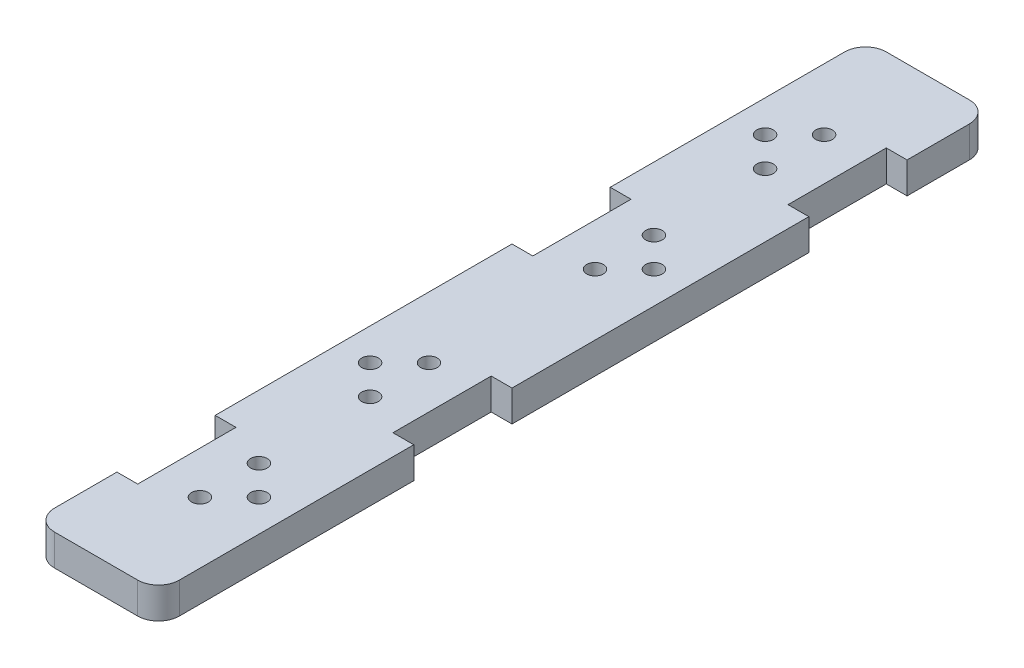
from build123d import *

# Parameters (mm, degrees)
BOSS_EXTRUDE1_DEPTH = 9.525
CUT_EXTRUDE1_REACH  = 11.525
SKETCH2_R           = 2.54
SKETCH2_W           = 6.35
SKETCH2_H           = 30


with BuildPart() as part:
    # Sketch1 → Boss-Extrude1 (new body)
    with BuildSketch(Plane(origin=(0, 0, 0), x_dir=(1, 0, 0), z_dir=(0, 1, 0))):
        with BuildLine():
            Line((6.35, 0), (31.75, 0))
            ThreePointArc((31.75, 0), (36.240128061, 1.859871939), (38.1, 6.35))
            Line((38.1, 6.35), (38.1, 247.65))
            ThreePointArc((38.1, 247.65), (36.240128061, 252.140128061), (31.75, 254))
            Line((31.75, 254), (6.35, 254))
            ThreePointArc((6.35, 254), (1.859871939, 252.140128061), (0, 247.65))
            Line((0, 247.65), (0, 6.35))
            ThreePointArc((0, 6.35), (1.859871939, 1.859871939), (6.35, 0))
        make_face()
    extrude(amount=BOSS_EXTRUDE1_DEPTH)

    # Sketch2 → Cut-Extrude1 (cut, up to next)
    with BuildSketch(Plane(origin=(0, 9.525, 0), x_dir=(1, 0, 0), z_dir=(0, 1, 0)), mode=Mode.PRIVATE) as cut_extrude1_sk1:
        with Locations((28.34999918, 40.4)):
            Circle(SKETCH2_R)
    cut_extrude1_tool1 = extrude(cut_extrude1_sk1.sketch, amount=-CUT_EXTRUDE1_REACH, mode=Mode.PRIVATE) & part.part
    add(cut_extrude1_tool1.solids().sort_by_distance((28.349999, 9.525, -40.4))[0], mode=Mode.SUBTRACT)
    # Sketch2 → Cut-Extrude1 (cut, up to next)
    with BuildSketch(Plane(origin=(0, 9.525, 0), x_dir=(1, 0, 0), z_dir=(0, 1, 0)), mode=Mode.PRIVATE) as cut_extrude1_sk2:
        with Locations((19.3499994, 49.39999978)):
            Circle(SKETCH2_R)
    cut_extrude1_tool2 = extrude(cut_extrude1_sk2.sketch, amount=-CUT_EXTRUDE1_REACH, mode=Mode.PRIVATE) & part.part
    add(cut_extrude1_tool2.solids().sort_by_distance((19.349999, 9.525, -49.4))[0], mode=Mode.SUBTRACT)
    # Sketch2 → Cut-Extrude1 (cut, up to next)
    with BuildSketch(Plane(origin=(0, 9.525, 0), x_dir=(1, 0, 0), z_dir=(0, 1, 0)), mode=Mode.PRIVATE) as cut_extrude1_sk3:
        with Locations((19.3499994, 31.40000022)):
            Circle(SKETCH2_R)
    cut_extrude1_tool3 = extrude(cut_extrude1_sk3.sketch, amount=-CUT_EXTRUDE1_REACH, mode=Mode.PRIVATE) & part.part
    add(cut_extrude1_tool3.solids().sort_by_distance((19.349999, 9.525, -31.4))[0], mode=Mode.SUBTRACT)
    # Sketch2 → Cut-Extrude1 (cut, up to next)
    with BuildSketch(Plane(origin=(0, 9.525, 0), x_dir=(1, 0, 0), z_dir=(0, 1, 0)), mode=Mode.PRIVATE) as cut_extrude1_sk4:
        with Locations((28.34999918, 161.05)):
            Circle(SKETCH2_R)
    cut_extrude1_tool4 = extrude(cut_extrude1_sk4.sketch, amount=-CUT_EXTRUDE1_REACH, mode=Mode.PRIVATE) & part.part
    add(cut_extrude1_tool4.solids().sort_by_distance((28.349999, 9.525, -161.05))[0], mode=Mode.SUBTRACT)
    # Sketch2 → Cut-Extrude1 (cut, up to next)
    with BuildSketch(Plane(origin=(0, 9.525, 0), x_dir=(1, 0, 0), z_dir=(0, 1, 0)), mode=Mode.PRIVATE) as cut_extrude1_sk5:
        with Locations((19.3499994, 170.04999978)):
            Circle(SKETCH2_R)
    cut_extrude1_tool5 = extrude(cut_extrude1_sk5.sketch, amount=-CUT_EXTRUDE1_REACH, mode=Mode.PRIVATE) & part.part
    add(cut_extrude1_tool5.solids().sort_by_distance((19.349999, 9.525, -170.05))[0], mode=Mode.SUBTRACT)
    # Sketch2 → Cut-Extrude1 (cut, up to next)
    with BuildSketch(Plane(origin=(0, 9.525, 0), x_dir=(1, 0, 0), z_dir=(0, 1, 0)), mode=Mode.PRIVATE) as cut_extrude1_sk6:
        with Locations((19.3499994, 152.05000022)):
            Circle(SKETCH2_R)
    cut_extrude1_tool6 = extrude(cut_extrude1_sk6.sketch, amount=-CUT_EXTRUDE1_REACH, mode=Mode.PRIVATE) & part.part
    add(cut_extrude1_tool6.solids().sort_by_distance((19.349999, 9.525, -152.05))[0], mode=Mode.SUBTRACT)
    # Sketch2 → Cut-Extrude1 (cut, up to next)
    with BuildSketch(Plane(origin=(0, 9.525, 0), x_dir=(1, 0, 0), z_dir=(0, 1, 0)), mode=Mode.PRIVATE) as cut_extrude1_sk7:
        with Locations((9.75000082, 213.6)):
            Circle(SKETCH2_R)
    cut_extrude1_tool7 = extrude(cut_extrude1_sk7.sketch, amount=-CUT_EXTRUDE1_REACH, mode=Mode.PRIVATE) & part.part
    add(cut_extrude1_tool7.solids().sort_by_distance((9.750001, 9.525, -213.6))[0], mode=Mode.SUBTRACT)
    # Sketch2 → Cut-Extrude1 (cut, up to next)
    with BuildSketch(Plane(origin=(0, 9.525, 0), x_dir=(1, 0, 0), z_dir=(0, 1, 0)), mode=Mode.PRIVATE) as cut_extrude1_sk8:
        with Locations((18.7500006, 222.59999978)):
            Circle(SKETCH2_R)
    cut_extrude1_tool8 = extrude(cut_extrude1_sk8.sketch, amount=-CUT_EXTRUDE1_REACH, mode=Mode.PRIVATE) & part.part
    add(cut_extrude1_tool8.solids().sort_by_distance((18.750001, 9.525, -222.6))[0], mode=Mode.SUBTRACT)
    # Sketch2 → Cut-Extrude1 (cut, up to next)
    with BuildSketch(Plane(origin=(0, 9.525, 0), x_dir=(1, 0, 0), z_dir=(0, 1, 0)), mode=Mode.PRIVATE) as cut_extrude1_sk9:
        with Locations((18.7500006, 204.60000022)):
            Circle(SKETCH2_R)
    cut_extrude1_tool9 = extrude(cut_extrude1_sk9.sketch, amount=-CUT_EXTRUDE1_REACH, mode=Mode.PRIVATE) & part.part
    add(cut_extrude1_tool9.solids().sort_by_distance((18.750001, 9.525, -204.6))[0], mode=Mode.SUBTRACT)
    # Sketch2 → Cut-Extrude1 (cut, up to next)
    with BuildSketch(Plane(origin=(0, 9.525, 0), x_dir=(1, 0, 0), z_dir=(0, 1, 0)), mode=Mode.PRIVATE) as cut_extrude1_sk10:
        with Locations((9.75000082, 92.95)):
            Circle(SKETCH2_R)
    cut_extrude1_tool10 = extrude(cut_extrude1_sk10.sketch, amount=-CUT_EXTRUDE1_REACH, mode=Mode.PRIVATE) & part.part
    add(cut_extrude1_tool10.solids().sort_by_distance((9.750001, 9.525, -92.95))[0], mode=Mode.SUBTRACT)
    # Sketch2 → Cut-Extrude1 (cut, up to next)
    with BuildSketch(Plane(origin=(0, 9.525, 0), x_dir=(1, 0, 0), z_dir=(0, 1, 0)), mode=Mode.PRIVATE) as cut_extrude1_sk11:
        with Locations((18.7500006, 101.94999978)):
            Circle(SKETCH2_R)
    cut_extrude1_tool11 = extrude(cut_extrude1_sk11.sketch, amount=-CUT_EXTRUDE1_REACH, mode=Mode.PRIVATE) & part.part
    add(cut_extrude1_tool11.solids().sort_by_distance((18.750001, 9.525, -101.95))[0], mode=Mode.SUBTRACT)
    # Sketch2 → Cut-Extrude1 (cut, up to next)
    with BuildSketch(Plane(origin=(0, 9.525, 0), x_dir=(1, 0, 0), z_dir=(0, 1, 0)), mode=Mode.PRIVATE) as cut_extrude1_sk12:
        with Locations((18.7500006, 83.95000022)):
            Circle(SKETCH2_R)
    cut_extrude1_tool12 = extrude(cut_extrude1_sk12.sketch, amount=-CUT_EXTRUDE1_REACH, mode=Mode.PRIVATE) & part.part
    add(cut_extrude1_tool12.solids().sort_by_distance((18.750001, 9.525, -83.95))[0], mode=Mode.SUBTRACT)
    # Sketch2 → Cut-Extrude1 (cut, up to next)
    with BuildSketch(Plane(origin=(0, 9.525, 0), x_dir=(1, 0, 0), z_dir=(0, 1, 0)), mode=Mode.PRIVATE) as cut_extrude1_sk13:
        with Locations((3.175, 40.4)):
            Rectangle(SKETCH2_W, SKETCH2_H)
    cut_extrude1_tool13 = extrude(cut_extrude1_sk13.sketch, amount=-CUT_EXTRUDE1_REACH, mode=Mode.PRIVATE) & part.part
    add(cut_extrude1_tool13.solids().sort_by_distance((3.175, 9.525, -40.4))[0], mode=Mode.SUBTRACT)
    # Sketch2 → Cut-Extrude1 (cut, up to next)
    with BuildSketch(Plane(origin=(0, 9.525, 0), x_dir=(1, 0, 0), z_dir=(0, 1, 0)), mode=Mode.PRIVATE) as cut_extrude1_sk14:
        with Locations((3.175, 161.05)):
            Rectangle(SKETCH2_W, SKETCH2_H)
    cut_extrude1_tool14 = extrude(cut_extrude1_sk14.sketch, amount=-CUT_EXTRUDE1_REACH, mode=Mode.PRIVATE) & part.part
    add(cut_extrude1_tool14.solids().sort_by_distance((3.175, 9.525, -161.05))[0], mode=Mode.SUBTRACT)
    # Sketch2 → Cut-Extrude1 (cut, up to next)
    with BuildSketch(Plane(origin=(0, 9.525, 0), x_dir=(1, 0, 0), z_dir=(0, 1, 0)), mode=Mode.PRIVATE) as cut_extrude1_sk15:
        with Locations((34.925, 213.6)):
            Rectangle(SKETCH2_W, SKETCH2_H)
    cut_extrude1_tool15 = extrude(cut_extrude1_sk15.sketch, amount=-CUT_EXTRUDE1_REACH, mode=Mode.PRIVATE) & part.part
    add(cut_extrude1_tool15.solids().sort_by_distance((34.925, 9.525, -213.6))[0], mode=Mode.SUBTRACT)
    # Sketch2 → Cut-Extrude1 (cut, up to next)
    with BuildSketch(Plane(origin=(0, 9.525, 0), x_dir=(1, 0, 0), z_dir=(0, 1, 0)), mode=Mode.PRIVATE) as cut_extrude1_sk16:
        with Locations((34.925, 92.95)):
            Rectangle(SKETCH2_W, SKETCH2_H)
    cut_extrude1_tool16 = extrude(cut_extrude1_sk16.sketch, amount=-CUT_EXTRUDE1_REACH, mode=Mode.PRIVATE) & part.part
    add(cut_extrude1_tool16.solids().sort_by_distance((34.925, 9.525, -92.95))[0], mode=Mode.SUBTRACT)


solid = part.part
